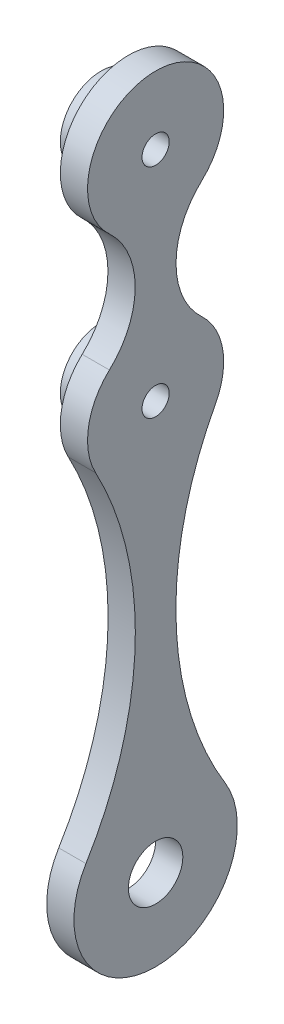
from build123d import *

# Parameters (mm, degrees)
SKETCH1_R           = 10
BOSS_EXTRUDE1_DEPTH = 10
SKETCH3_R           = 15
BOSS_EXTRUDE3_DEPTH = 10
SKETCH4_R           = 5
CUT_EXTRUDE1_DEPTH  = 20


with BuildPart() as part:
    # Sketch1 → Boss-Extrude1 (new body)
    with BuildSketch(Plane(origin=(0, 0, 0), x_dir=(0, 0, -1), z_dir=(1, 0, 0))):
        with BuildLine():
            ThreePointArc((16.967213115, -18.360655738), (0, 25), (-16.967213115, -18.360655738))
            ThreePointArc((-16.967213115, -18.360655738), (-7.5, -40), (-16.967213115, -61.639344262))
            ThreePointArc((-16.967213115, -61.639344262), (-24.653637732, -75.852935186), (-22.040471077, -91.799052281))
            ThreePointArc((-22.040471077, -91.799052281), (-7.5, -153.539335996), (-25.58571686, -214.33567452))
            ThreePointArc((-25.58571686, -214.33567452), (0, -260), (25.58571686, -214.33567452))
            ThreePointArc((25.58571686, -214.33567452), (7.5, -153.539335996), (22.040471077, -91.799052281))
            ThreePointArc((22.040471077, -91.799052281), (24.653637732, -75.852935186), (16.967213115, -61.639344262))
            ThreePointArc((16.967213115, -61.639344262), (7.5, -40), (16.967213115, -18.360655738))
        make_face()
        with Locations((0, -230)):
            Circle(SKETCH1_R, mode=Mode.SUBTRACT)
    extrude(amount=BOSS_EXTRUDE1_DEPTH)

    # Sketch3 → Boss-Extrude3 (add)
    with BuildSketch(Plane.ZY):
        Circle(SKETCH3_R)
        with Locations((0, -80)):
            Circle(SKETCH3_R)
    extrude(amount=BOSS_EXTRUDE3_DEPTH)

    # Sketch4 → Cut-Extrude1 (cut)
    with BuildSketch(Plane.ZY.offset(10)):
        with Locations((0, -80)):
            Circle(SKETCH4_R)
        Circle(SKETCH4_R)
    extrude(amount=-CUT_EXTRUDE1_DEPTH, mode=Mode.SUBTRACT)


solid = part.part
